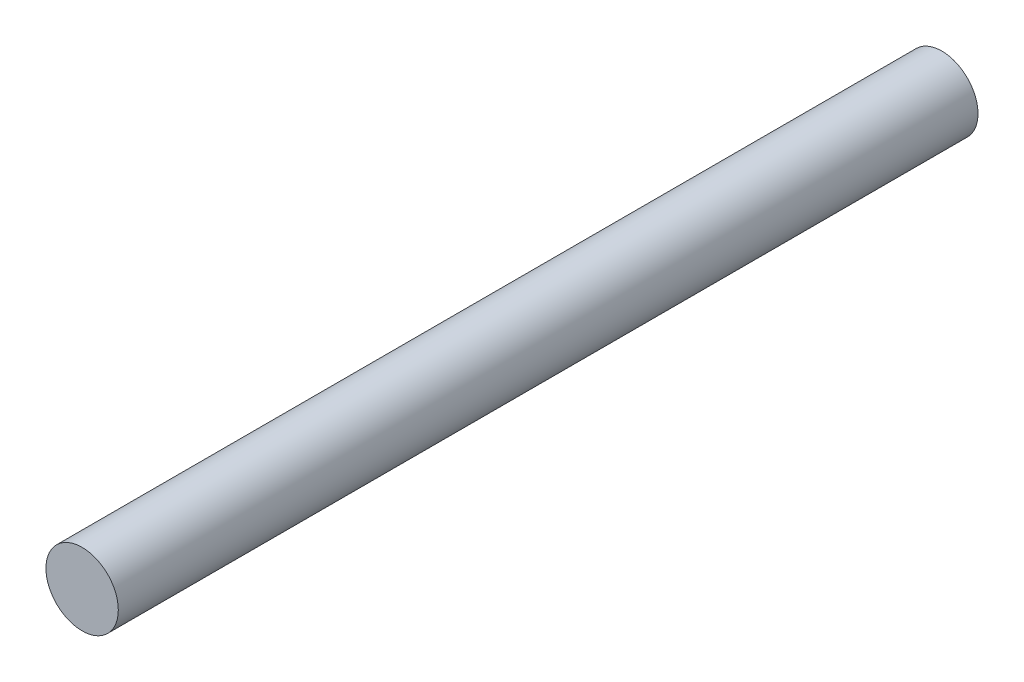
from build123d import *

# Parameters (mm, degrees)
SKETCH3_R           = 78.35
BOSS_EXTRUDE1_DEPTH = 1861.1


with BuildPart() as part:
    # Sketch3 → Boss-Extrude1 (new body)
    with BuildSketch(Plane.XY):
        Circle(SKETCH3_R)
    extrude(amount=-BOSS_EXTRUDE1_DEPTH)


solid = part.part
